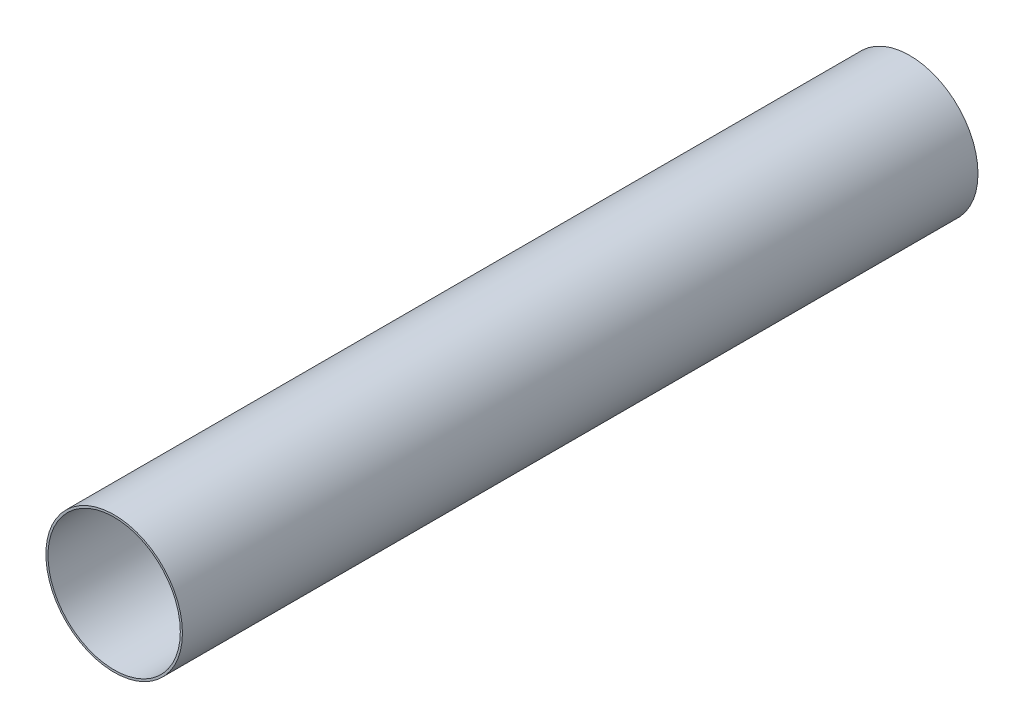
from build123d import *

# Parameters (mm, degrees)
SKETCH1_R           = 65.405
SKETCH1_R_2         = 63.373
BOSS_EXTRUDE1_DEPTH = 381


with BuildPart() as part:
    # Sketch1 → Boss-Extrude1 (new body, symmetric)
    with BuildSketch(Plane.XY):
        Circle(SKETCH1_R)
        Circle(SKETCH1_R_2, mode=Mode.SUBTRACT)
    extrude(amount=BOSS_EXTRUDE1_DEPTH, both=True)


solid = part.part
